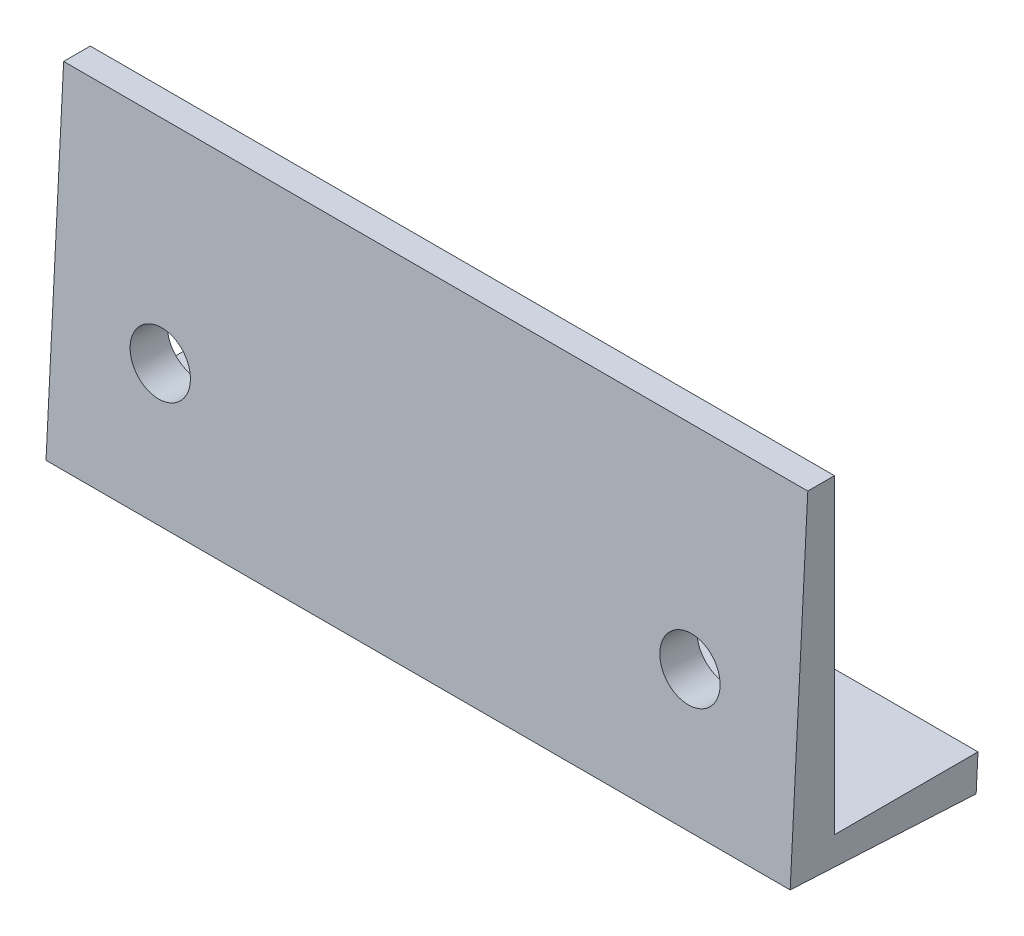
from build123d import *

# Parameters (mm, degrees)
SKETCH1_W           = 84
SKETCH1_H           = 38
BOSS_EXTRUDE1_DEPTH = 5
SKETCH2_W           = 84
SKETCH2_H           = 42
CUT_REVOLVE1_ANGLE  = 3
SKETCH5_W           = 84
SKETCH5_H           = 5
REVOLVE1_ANGLE      = 3
BOSS_EXTRUDE3_DEPTH = 84
SKETCH4_R           = 3.4
CUT_EXTRUDE1_DEPTH  = 10


with BuildPart() as part:
    # Sketch1 → Boss-Extrude1 (new body)
    with BuildSketch(Plane.XY):
        Rectangle(SKETCH1_W, SKETCH1_H)
    extrude(amount=BOSS_EXTRUDE1_DEPTH)

    # Sketch2 → Cut-Revolve1 (revolve, cut)
    with BuildSketch(Plane.XY.offset(5)):
        with Locations((0, 2)):
            Rectangle(SKETCH2_W, SKETCH2_H)
    revolve(axis=Axis((-42, -19, 5), (-1, 0, 0)), revolution_arc=CUT_REVOLVE1_ANGLE, mode=Mode.SUBTRACT)

    # Sketch5 → Revolve1 (revolve)
    with BuildSketch(Plane.XZ.offset(19)):
        with Locations((0, 2.5)):
            Rectangle(SKETCH5_W, SKETCH5_H)
    revolve(axis=Axis((-42, -19, 5), (-1, 0, 0)), revolution_arc=REVOLVE1_ANGLE)

    # Sketch6 → Boss-Extrude3 (add)
    with BuildSketch(Plane(origin=(-42, 0, 0), x_dir=(0, -1, 0), z_dir=(-1, 0, 0))):
        Polygon((19.261679781, 0.006852326), (20.10020425, -15.993147674), (16.10020425, -16.202778791), (16.10020425, 0), align=None)
    extrude(amount=-BOSS_EXTRUDE3_DEPTH)

    # Sketch4 → Cut-Extrude1 (cut)
    with BuildSketch(Plane(origin=(0, 0.209279164, 3.993284337), x_dir=(1, 0, 0), z_dir=(0, 0.052335956, 0.998629535))):
        with Locations((29.895651858, -4.083491794)):
            Circle(SKETCH4_R)
        with Locations((-29.895651858, -4.083491794)):
            Circle(SKETCH4_R)
    extrude(amount=-CUT_EXTRUDE1_DEPTH, mode=Mode.SUBTRACT)


solid = part.part
